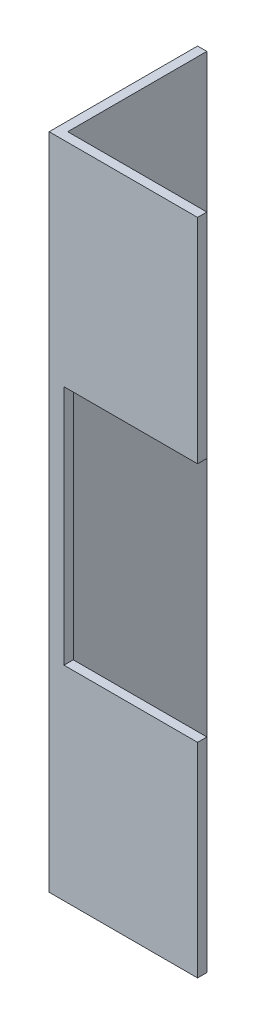
from build123d import *

# Parameters (mm, degrees)
BOSS_EXTRUDE1_DEPTH = 112.7125
SKETCH4_W           = 22.86
SKETCH4_H           = 41.275
CUT_EXTRUDE1_DEPTH  = 2.5875


with BuildPart() as part:
    # Sketch1 → Boss-Extrude1 (new body)
    with BuildSketch(Plane(origin=(0, 0, 0), x_dir=(1, 0, 0), z_dir=(0, 1, 0))):
        Polygon((0, 0), (0, 25.4), (1.5875, 25.4), (1.5875, 1.5875), (25.4, 1.5875), (25.4, 0), align=None)
    extrude(amount=BOSS_EXTRUDE1_DEPTH)

    # Sketch4 → Cut-Extrude1 (cut, through all)
    with BuildSketch(Plane(origin=(0, 0, -1.5875), x_dir=(-1, 0, 0), z_dir=(0, 0, -1))):
        with Locations((-13.97, 55.5625)):
            Rectangle(SKETCH4_W, SKETCH4_H)
    extrude(amount=-CUT_EXTRUDE1_DEPTH, mode=Mode.SUBTRACT)


solid = part.part
